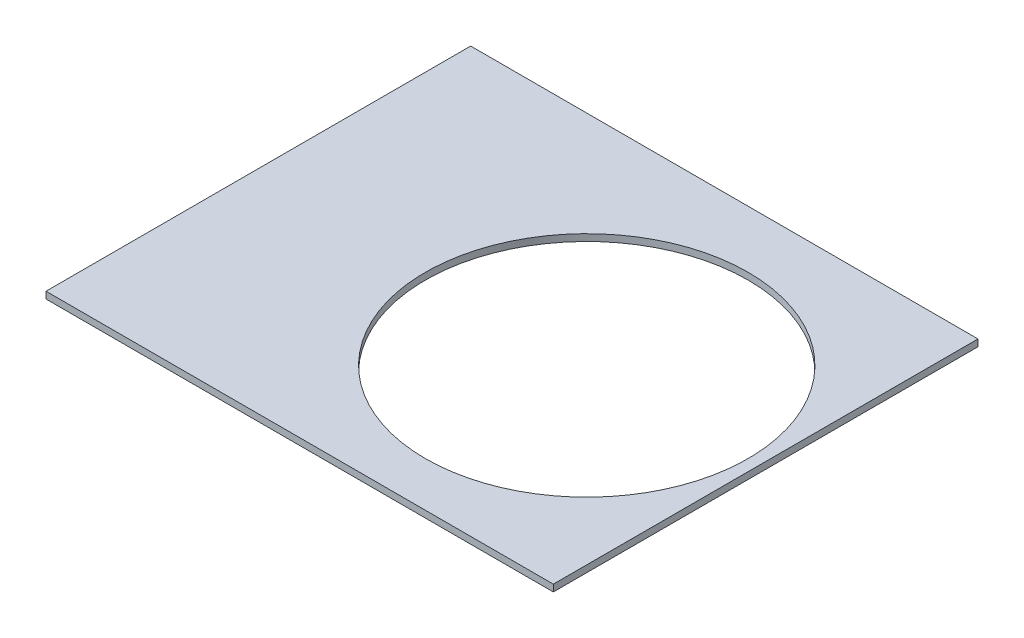
from build123d import *

# Parameters (mm, degrees)
SKETCH1_W               = 89.6
SKETCH1_H               = 75
BOSS_EXTRUDE1_DEPTH     = 1.2
SKETCH2_R               = 28.5
CUT_EXTRUDE1_DEPTH      = 1
CUT_EXTRUDE1_DEPTH_BACK = 2.2


with BuildPart() as part:
    # Sketch1 → Boss-Extrude1 (new body)
    with BuildSketch(Plane(origin=(0, 0, 0), x_dir=(1, 0, 0), z_dir=(0, 1, 0))):
        Rectangle(SKETCH1_W, SKETCH1_H)
    extrude(amount=BOSS_EXTRUDE1_DEPTH)

    # Sketch2 → Cut-Extrude1 (cut, two sides)
    with BuildSketch(Plane(origin=(0, 1.2, 0), x_dir=(1, 0, 0), z_dir=(0, 1, 0))) as cut_extrude1_sk:
        with Locations((14.3, -1.1)):
            Circle(SKETCH2_R)
    extrude(amount=CUT_EXTRUDE1_DEPTH, mode=Mode.SUBTRACT)
    extrude(cut_extrude1_sk.sketch, amount=-CUT_EXTRUDE1_DEPTH_BACK, mode=Mode.SUBTRACT)


solid = part.part
